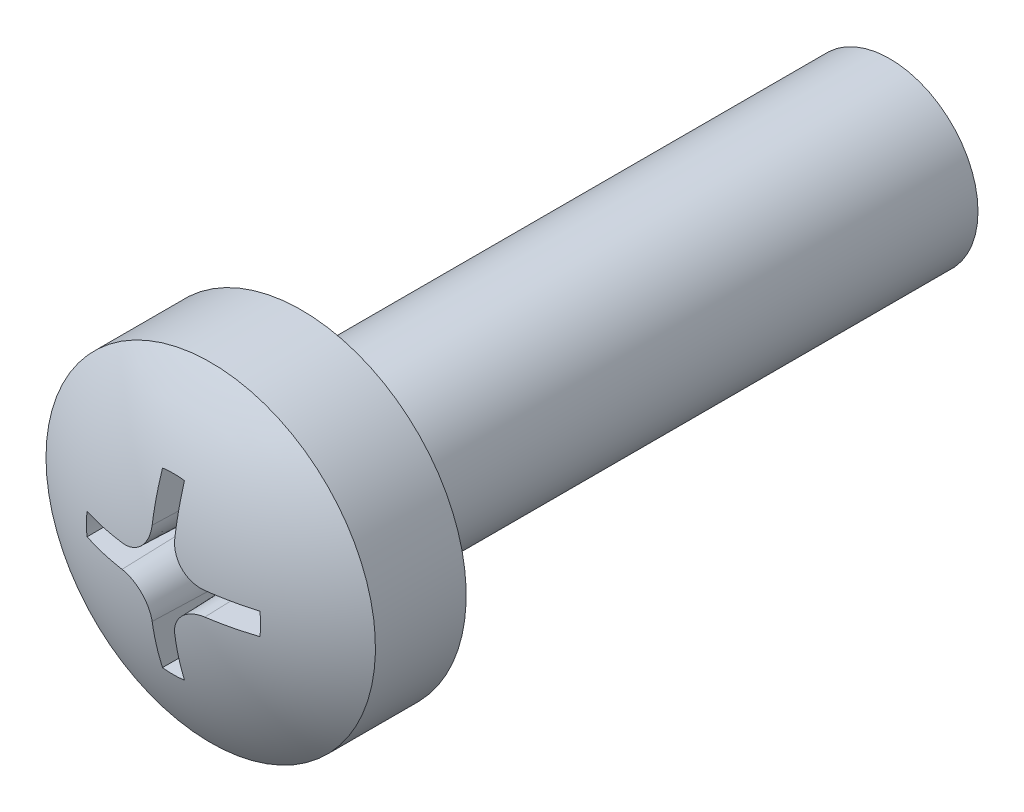
from build123d import *

# Parameters (mm, degrees)
SKETCH1_R          = 1.5
BASE_EXTRUDE_DEPTH = 10
CUT_EXTRUDE1_DEPTH = 1.799999969
CUT_EXTRUDE1_TAPER = 2


with BuildPart() as part:
    # Sketch1 → Base-Extrude (new body)
    with BuildSketch(Plane.XY):
        Circle(SKETCH1_R)
    extrude(amount=BASE_EXTRUDE_DEPTH)

    # Sketch6 → Boss-Revolve2 (revolve)
    with BuildSketch(Plane(origin=(0, 0, 0), x_dir=(1, 0, 0), z_dir=(0, 1, 0))):
        with BuildLine():
            Line((0, -10), (2.7999999, -10))
            Line((2.7999999, -10), (2.7999999, -11.54246308))
            ThreePointArc((2.7999999, -11.54246308), (1.46418655, -12.180811406), (0, -12.4))
            Line((0, -12.4), (0, -10))
        make_face()
    revolve(axis=Axis((0, 0, -0.393620135), (0, 0, 1)))

    # Sketch7 → Cut-Extrude1 (cut)
    with BuildSketch(Plane(origin=(0, 0, 12.7000001), x_dir=(-1, 0, 0), z_dir=(0, 0, -1))):
        with BuildLine():
            ThreePointArc((0.205000004, 1.48592565), (0, 1.500000013), (-0.205000004, 1.48592565))
            Line((-0.205000004, 1.48592565), (-0.205000004, 0.708178558))
            ThreePointArc((-0.205000004, 0.708178558), (-0.35072876, 0.355344481), (-0.702967546, 0.208182689))
            Line((-0.702967546, 0.208182689), (-1.48592565, 0.205000004))
            ThreePointArc((-1.48592565, 0.205000004), (-1.500000013, 0), (-1.48592565, -0.205000004))
            Line((-1.48592565, -0.205000004), (-0.702967546, -0.208182689))
            ThreePointArc((-0.702967546, -0.208182689), (-0.35072876, -0.355344481), (-0.205000004, -0.708178558))
            Line((-0.205000004, -0.708178558), (-0.205000004, -1.48592565))
            ThreePointArc((-0.205000004, -1.48592565), (0, -1.500000013), (0.205000004, -1.48592565))
            Line((0.205000004, -1.48592565), (0.205000004, -0.708178558))
            ThreePointArc((0.205000004, -0.708178558), (0.35072876, -0.355344481), (0.702967546, -0.208182689))
            Line((0.702967546, -0.208182689), (1.48592565, -0.205000004))
            ThreePointArc((1.48592565, -0.205000004), (1.500000013, 0), (1.48592565, 0.205000004))
            Line((1.48592565, 0.205000004), (0.702967546, 0.208182689))
            ThreePointArc((0.702967546, 0.208182689), (0.35072876, 0.355344481), (0.205000004, 0.708178558))
            Line((0.205000004, 0.708178558), (0.205000004, 1.48592565))
        make_face()
    extrude(amount=CUT_EXTRUDE1_DEPTH, taper=CUT_EXTRUDE1_TAPER, mode=Mode.SUBTRACT)


solid = part.part
